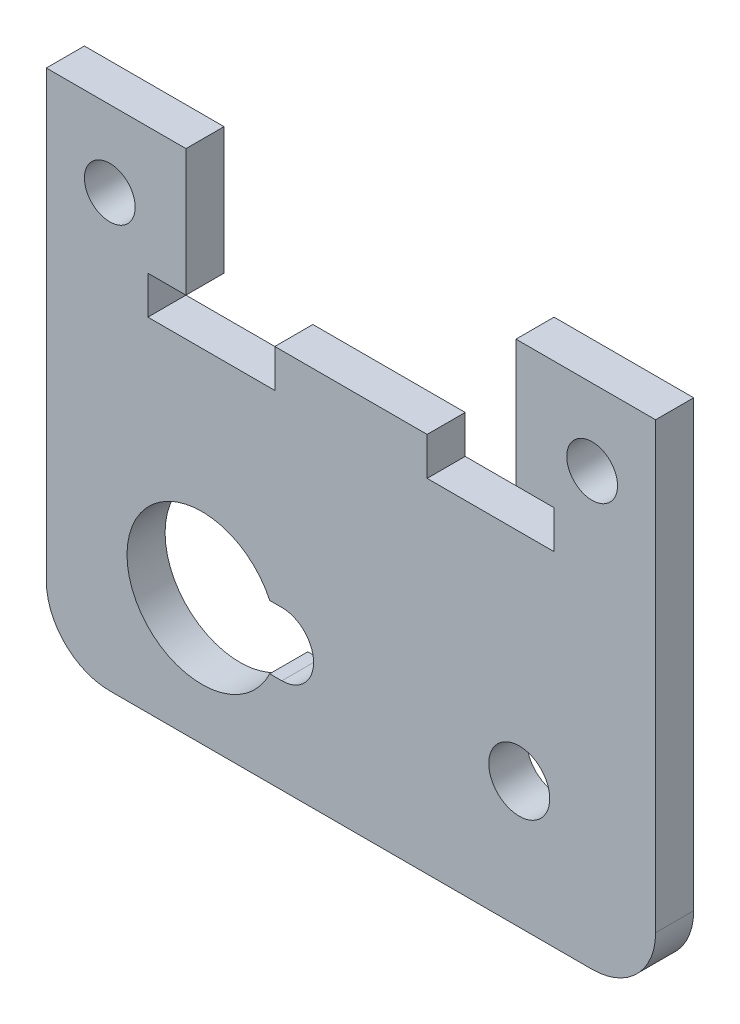
from build123d import *

# Parameters (mm, degrees)
MODEL_R                 = 2.4
MODEL_R_2               = 2
SALIENTE_EXTRUIR1_DEPTH = 3


with BuildPart() as part:
    # Model → Saliente-Extruir1 (new body)
    with BuildSketch(Plane.XY):
        with BuildLine():
            Line((60.128031424, 43.810084434), (60.128031424, 26.988429812))
            Line((60.128031424, 26.988429812), (60.128031424, 8.810084434))
            ThreePointArc((60.128031424, 8.810084434), (61.592497518, 5.274550528), (65.128031424, 3.810084434))
            Line((65.128031424, 3.810084434), (103.128031424, 3.810084434))
            ThreePointArc((103.128031424, 3.810084434), (106.66356533, 5.274550528), (108.128031424, 8.810084434))
            Line((108.128031424, 8.810084434), (108.128031424, 43.810084434))
            Line((108.128031424, 43.810084434), (97.128031424, 43.810084434))
            Line((97.128031424, 43.810084434), (97.128031424, 33.810084434))
            Line((97.128031424, 33.810084434), (100.128031424, 33.810084434))
            Line((100.128031424, 33.810084434), (100.128031424, 30.810084434))
            Line((100.128031424, 30.810084434), (90.128031424, 30.810084434))
            Line((90.128031424, 30.810084434), (90.128031424, 33.810084434))
            Line((90.128031424, 33.810084434), (78.128031424, 33.810084434))
            Line((78.128031424, 33.810084434), (78.128031424, 30.810084434))
            Line((78.128031424, 30.810084434), (68.128031424, 30.810084434))
            Line((68.128031424, 30.810084434), (68.128031424, 33.810084434))
            Line((68.128031424, 33.810084434), (71.128031424, 33.810084434))
            Line((71.128031424, 33.810084434), (71.128031424, 43.810084434))
            Line((71.128031424, 43.810084434), (60.128031424, 43.810084434))
        make_face()
        with Locations((97.386085589, 13.789032772)):
            Circle(MODEL_R, mode=Mode.SUBTRACT)
        with Locations((65.128031424, 37.810084434)):
            Circle(MODEL_R_2, mode=Mode.SUBTRACT)
        with Locations((103.128031424, 37.810084434)):
            Circle(MODEL_R_2, mode=Mode.SUBTRACT)
        with BuildLine():
            Line((78.683481489, 11.277984768), (77.72633505, 11.277984768))
            ThreePointArc((77.72633505, 11.277984768), (66.483480743, 13.783830387), (77.728934453, 16.277984768))
            Line((77.728934453, 16.277984768), (78.683481489, 16.277984768))
            ThreePointArc((78.683481489, 16.277984768), (81.183481489, 13.777984768), (78.683481489, 11.277984768))
        make_face(mode=Mode.SUBTRACT)
    extrude(amount=SALIENTE_EXTRUIR1_DEPTH)


solid = part.part
